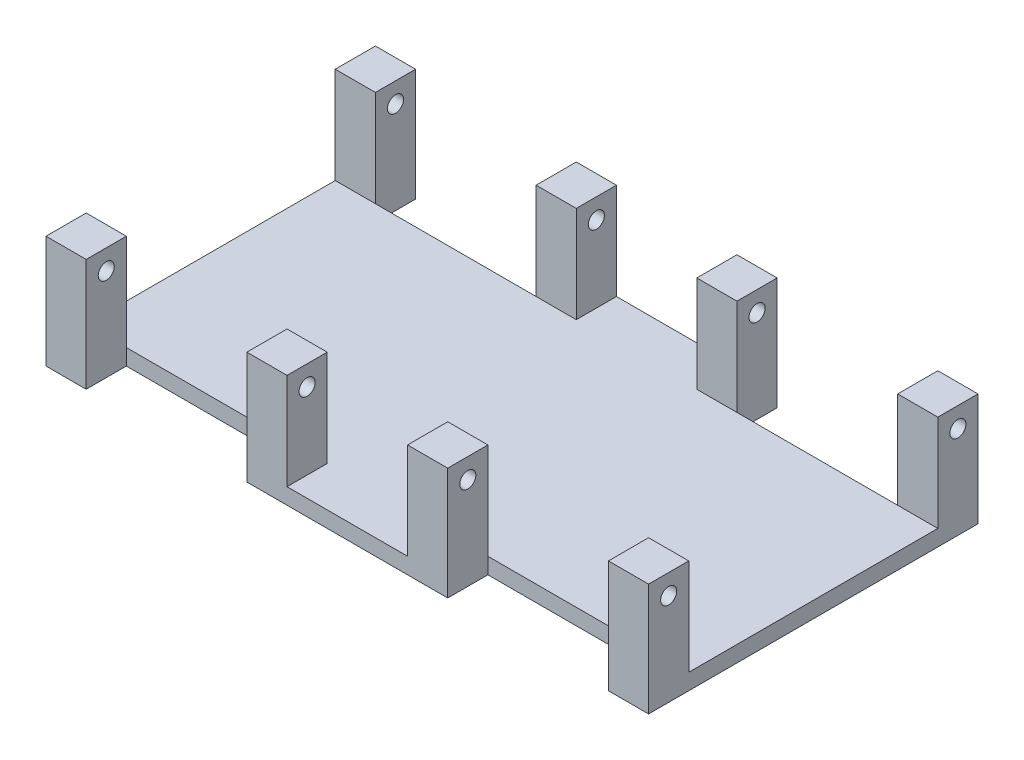
from build123d import *

# Parameters (mm, degrees)
SKETCH1_W           = 130
SKETCH1_H           = 82
BOSS_EXTRUDE1_DEPTH = 4
SKETCH2_W           = 40
SKETCH2_H           = 10
CUT_EXTRUDE1_DEPTH  = 24
BOSS_EXTRUDE2_DEPTH = 4
SKETCH4_W           = 10
SKETCH4_H           = 10
BOSS_EXTRUDE3_DEPTH = 24
SKETCH5_R           = 2
CUT_EXTRUDE2_DEPTH  = 151


with BuildPart() as part:
    # Sketch1 → Boss-Extrude1 (new body)
    with BuildSketch(Plane(origin=(0, 0, 0), x_dir=(1, 0, 0), z_dir=(0, 1, 0))):
        Rectangle(SKETCH1_W, SKETCH1_H)
    extrude(amount=BOSS_EXTRUDE1_DEPTH)

    # Sketch2 → Cut-Extrude1 (cut)
    with BuildSketch(Plane(origin=(0, 4, 0), x_dir=(1, 0, 0), z_dir=(0, 1, 0))):
        with Locations((-45, 36)):
            Rectangle(SKETCH2_W, SKETCH2_H)
        with Locations((45, 36)):
            Rectangle(SKETCH2_W, SKETCH2_H)
        with Locations((45, -36)):
            Rectangle(SKETCH2_W, SKETCH2_H)
        with Locations((-45, -36)):
            Rectangle(SKETCH2_W, SKETCH2_H)
    extrude(amount=-CUT_EXTRUDE1_DEPTH, mode=Mode.SUBTRACT)

    # Sketch3 → Boss-Extrude2 (add)
    with BuildSketch(Plane(origin=(0, 4, 0), x_dir=(1, 0, 0), z_dir=(0, 1, 0))):
        Polygon((-65, -31), (-65, 31), (-65, 41), (-75, 41), (-75, -41), (-65, -41), align=None)
        Polygon((75, 41), (65, 41), (65, 31), (65, -31), (65, -41), (75, -41), align=None)
    extrude(amount=-BOSS_EXTRUDE2_DEPTH)

    # Sketch4 → Boss-Extrude3 (add)
    with BuildSketch(Plane(origin=(0, 4, 0), x_dir=(1, 0, 0), z_dir=(0, 1, 0))):
        with Locations((-70, 36)):
            Rectangle(SKETCH4_W, SKETCH4_H)
        with Locations((-20, 36)):
            Rectangle(SKETCH4_W, SKETCH4_H)
        with Locations((20, 36)):
            Rectangle(SKETCH4_W, SKETCH4_H)
        with Locations((70, 36)):
            Rectangle(SKETCH4_W, SKETCH4_H)
        with Locations((70, -36)):
            Rectangle(SKETCH4_W, SKETCH4_H)
        with Locations((20, -36)):
            Rectangle(SKETCH4_W, SKETCH4_H)
        with Locations((-20, -36)):
            Rectangle(SKETCH4_W, SKETCH4_H)
        with Locations((-70, -36)):
            Rectangle(SKETCH4_W, SKETCH4_H)
    extrude(amount=BOSS_EXTRUDE3_DEPTH)

    # Sketch5 → Cut-Extrude2 (cut, through all)
    with BuildSketch(Plane.ZY.offset(75)):
        with Locations((-36, 23)):
            Circle(SKETCH5_R)
        with Locations((36, 23)):
            Circle(SKETCH5_R)
    extrude(amount=-CUT_EXTRUDE2_DEPTH, mode=Mode.SUBTRACT)


solid = part.part
